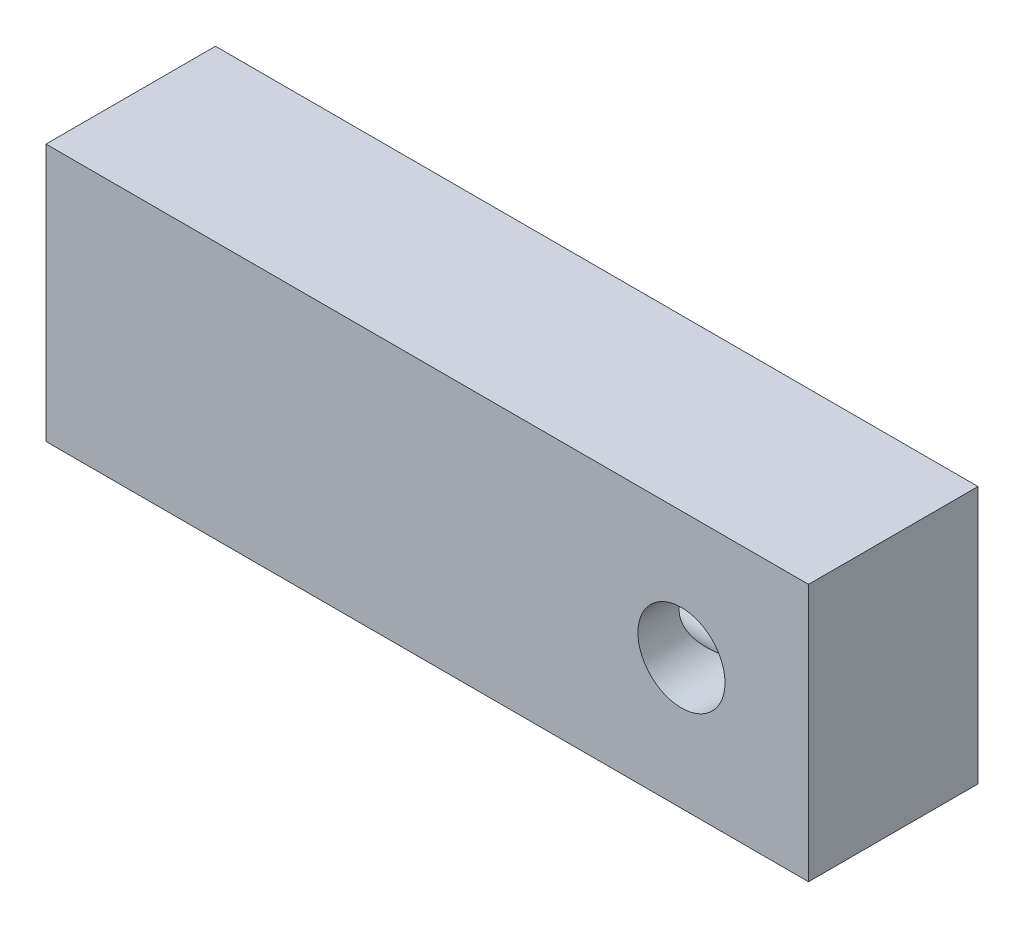
from build123d import *

# Parameters (mm, degrees)
SKETCH1_W                 = 28.575
SKETCH1_H                 = 9.652
BOSS_EXTRUDE1_DEPTH       = 6.35
F_4_CLEARANCE_HOLE1_D     = 3.2639
F_4_CLEARANCE_HOLE2_D     = 3.2639
F_4_CLEARANCE_HOLE2_DEPTH = 23.8115
F_4_CLEARANCE_HOLE2_TIP   = 0.980574487


with BuildPart() as part:
    # Sketch1 → Boss-Extrude1 (new body)
    with BuildSketch(Plane.XY):
        Rectangle(SKETCH1_W, SKETCH1_H)
    extrude(amount=BOSS_EXTRUDE1_DEPTH)

    # #4 Clearance Hole1 (through all)
    with Locations(Plane.XY.offset(6.35)):
        with Locations((9.525, 0.0635)):
            Hole(F_4_CLEARANCE_HOLE1_D / 2)

    # #4 Clearance Hole2
    with Locations(Plane.ZY.offset(14.2875)):
        with Locations((3.175, 0)):
            Hole(F_4_CLEARANCE_HOLE2_D / 2, depth=F_4_CLEARANCE_HOLE2_DEPTH)
            with Locations((0, 0, -(F_4_CLEARANCE_HOLE2_DEPTH + F_4_CLEARANCE_HOLE2_TIP / 2))):  # 118° drill point
                Cone(0, F_4_CLEARANCE_HOLE2_D / 2, F_4_CLEARANCE_HOLE2_TIP, mode=Mode.SUBTRACT)


solid = part.part
